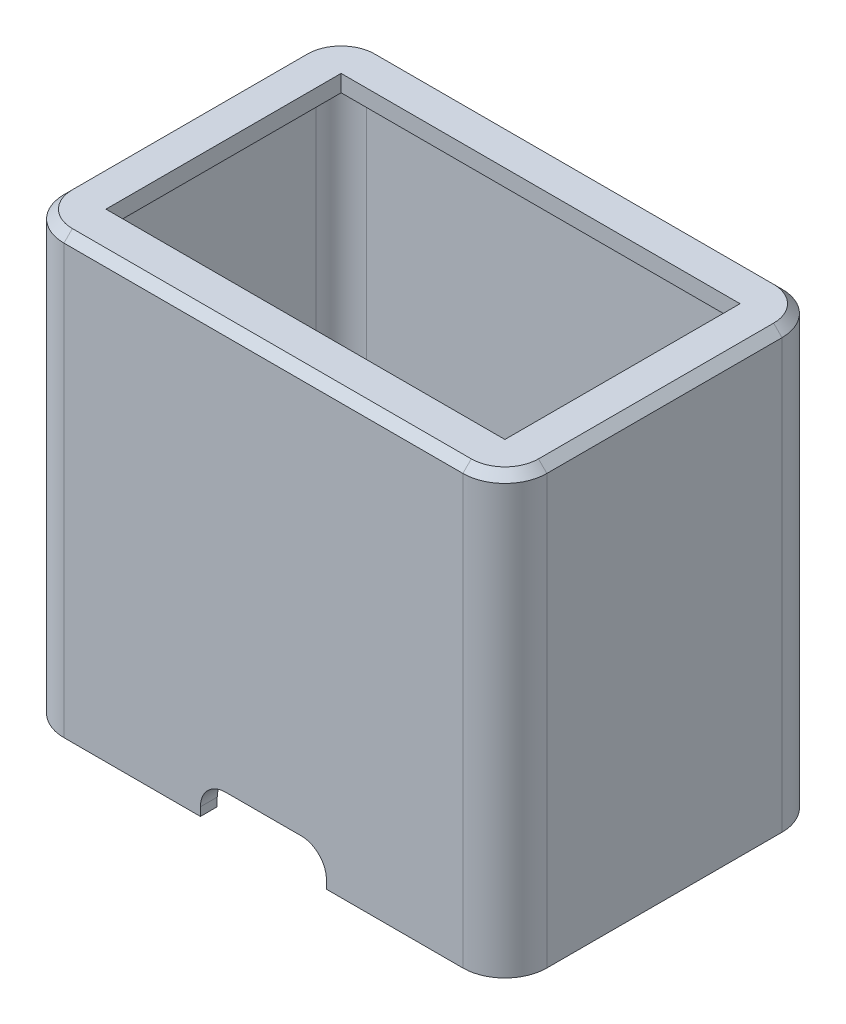
from build123d import *

# Parameters (mm, degrees)
SKETCH2_W           = 57.5
SKETCH2_H           = 38
SKETCH2_W_2         = 47.5
SKETCH2_H_2         = 28
BOSS_EXTRUDE1_DEPTH = 2
SKETCH3_W           = 57.5
SKETCH3_H           = 38
SKETCH3_W_2         = 53.5
SKETCH3_H_2         = 34
BOSS_EXTRUDE2_DEPTH = 50
FILLET1_R           = 3
FILLET2_R           = 5
SKETCH4_W           = 15
SKETCH4_H           = 4
CUT_EXTRUDE1_DEPTH  = 2
FILLET3_R           = 3
CHAMFER1_SIZE       = 1
SKETCH6_W           = 15
SKETCH6_H           = 8
SKETCH6_R           = 1.75
BOSS_EXTRUDE3_DEPTH = 2.5
FILLET4_R           = 3


with BuildPart() as part:
    # Sketch2 → Boss-Extrude1 (new body)
    with BuildSketch(Plane(origin=(0, 0, 0), x_dir=(1, 0, 0), z_dir=(0, 1, 0))):
        Rectangle(SKETCH2_W, SKETCH2_H)
        Rectangle(SKETCH2_W_2, SKETCH2_H_2, mode=Mode.SUBTRACT)
    extrude(amount=BOSS_EXTRUDE1_DEPTH)

    # Sketch3 → Boss-Extrude2 (add)
    with BuildSketch(Plane.XZ):
        Rectangle(SKETCH3_W, SKETCH3_H)
        Rectangle(SKETCH3_W_2, SKETCH3_H_2, mode=Mode.SUBTRACT)
    extrude(amount=BOSS_EXTRUDE2_DEPTH)

    # Fillet1
    fillet1_edges = [part.edges().sort_by_distance(p)[0] for p in [
        (26.75, -25, -17),
        (26.75, -25, 17),
        (-26.75, -25, 17),
        (-26.75, -25, -17),
    ]]
    fillet(fillet1_edges, radius=FILLET1_R)

    # Fillet2
    fillet2_edges = [part.edges().sort_by_distance(p)[0] for p in [
        (28.75, -24, 19),
        (-28.75, -24, 19),
        (-28.75, -24, -19),
        (28.75, -24, -19),
    ]]
    fillet(fillet2_edges, radius=FILLET2_R)

    # Sketch4 → Cut-Extrude1 (cut)
    with BuildSketch(Plane.XY.offset(19)):
        with Locations((0, -48)):
            Rectangle(SKETCH4_W, SKETCH4_H)
    extrude(amount=-CUT_EXTRUDE1_DEPTH, mode=Mode.SUBTRACT)

    # Fillet3
    fillet3_edges = [part.edges().sort_by_distance(p)[0] for p in [
        (7.5, -46, 18),
        (-7.5, -46, 18),
    ]]
    fillet(fillet3_edges, radius=FILLET3_R)

    # Chamfer1
    chamfer1_edges = [part.edges().sort_by_distance(p)[0] for p in [
        (0, 2, 19),
        (-28.75, 2, 0),
        (28.75, 2, 0),
        (0, 2, -19),
        (27.285533906, 2, 17.535533906),
        (27.285533906, 2, -17.535533906),
        (-27.285533906, 2, -17.535533906),
        (-27.285533906, 2, 17.535533906),
    ]]
    chamfer(chamfer1_edges, length=CHAMFER1_SIZE)

    # Sketch6 → Boss-Extrude3 (add)
    with BuildSketch(Plane.XZ.offset(50)):
        with Locations((-21.25, 0)):
            Rectangle(SKETCH6_W, SKETCH6_H)
        with Locations((-18.75, 0)):
            Circle(SKETCH6_R, mode=Mode.SUBTRACT)
    boss_extrude3 = extrude(amount=-BOSS_EXTRUDE3_DEPTH)

    # Mirror1: Boss-Extrude3 across plane
    add(boss_extrude3.mirror(Plane(origin=(0, 0, 0), x_dir=(0, 0, 1), z_dir=(1, 0, 0))))

    # Fillet4
    fillet4_edges = [part.edges().sort_by_distance(p)[0] for p in [
        (-26.75, -48.75, -4),
        (-26.75, -48.75, 4),
        (-13.75, -48.75, 4),
        (-13.75, -48.75, -4),
        (26.75, -48.75, 4),
        (26.75, -48.75, -4),
        (13.75, -48.75, -4),
        (13.75, -48.75, 4),
    ]]
    fillet(fillet4_edges, radius=FILLET4_R)


solid = part.part
